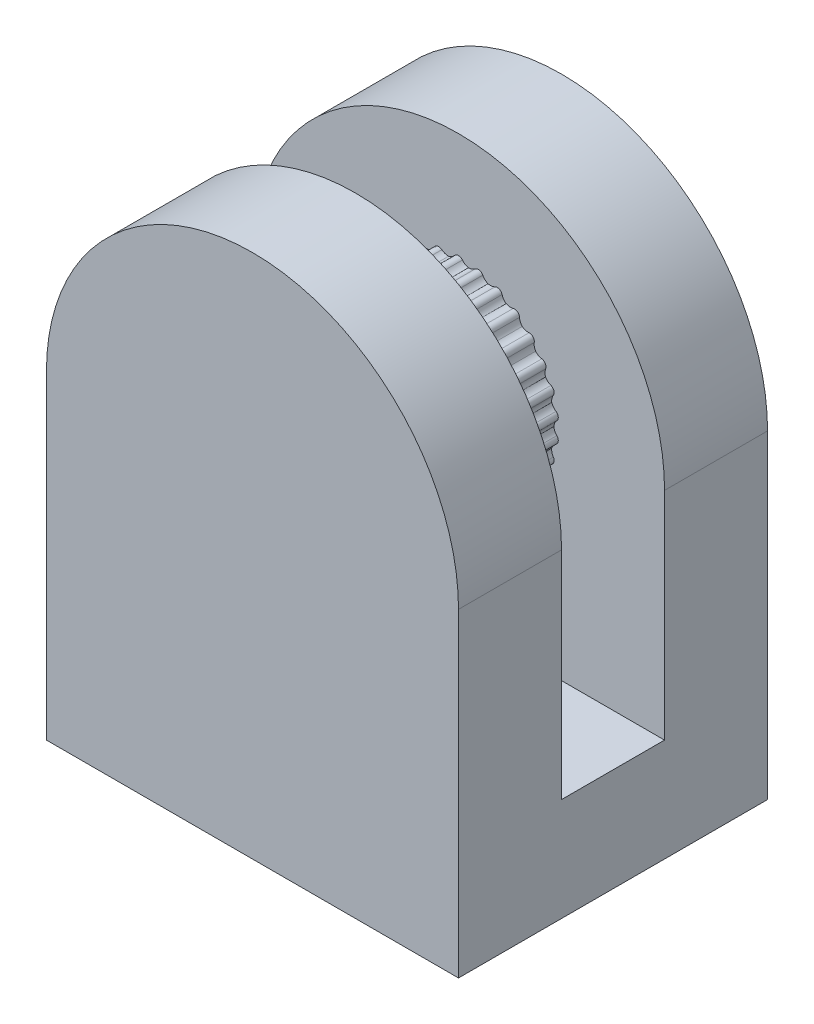
from build123d import *

# Parameters (mm, degrees)
BOSS_EXTRUDE1_DEPTH = 10
BOSS_EXTRUDE2_DEPTH = 10
SKETCH3_W           = 40
SKETCH3_H           = 10
BOSS_EXTRUDE3_DEPTH = 10


with BuildPart() as part:
    # Sketch1 → Boss-Extrude1 (new body)
    with BuildSketch(Plane.XY):
        with BuildLine():
            ThreePointArc((0.378650208, 9.55600532), (0, 9.736842105), (-0.378650208, 9.55600532))
            ThreePointArc((-0.378650208, 9.55600532), (-0.641665483, 9.327218092), (-0.967233833, 9.202615203))
            ThreePointArc((-0.967233833, 9.202615203), (-1.311594131, 9.256805753), (-1.616429431, 9.425909481))
            ThreePointArc((-1.616429431, 9.425909481), (-2.024403305, 9.524068744), (-2.357181016, 9.268457871))
            ThreePointArc((-2.357181016, 9.268457871), (-2.566881237, 8.989986242), (-2.85942874, 8.800416759))
            ThreePointArc((-2.85942874, 8.800416759), (-3.207530788, 8.781826585), (-3.540863348, 8.883856167))
            ThreePointArc((-3.540863348, 8.883856167), (-3.960330472, 8.895047877), (-4.232691702, 8.575834338))
            ThreePointArc((-4.232691702, 8.575834338), (-4.379911963, 8.259848855), (-4.62665289, 8.013597874))
            ThreePointArc((-4.62665289, 8.013597874), (-4.963282959, 7.923039454), (-5.310544545, 7.95353571))
            ThreePointArc((-5.310544545, 7.95353571), (-5.723172193, 7.877270735), (-5.923213451, 7.508405694))
            ThreePointArc((-5.923213451, 7.508405694), (-6.00151952, 7.168716439), (-6.191670107, 6.876546309))
            ThreePointArc((-6.191670107, 6.876546309), (-6.502115847, 6.717977481), (-6.848129462, 6.675607576))
            ThreePointArc((-6.848129462, 6.675607576), (-7.235883827, 6.515219062), (-7.354862349, 6.112823691))
            ThreePointArc((-7.354862349, 6.112823691), (-7.360831875, 5.764276714), (-7.48608163, 5.438956672))
            ThreePointArc((-7.48608163, 5.438956672), (-7.756775072, 5.219307655), (-8.086418262, 5.105923359))
            ThreePointArc((-8.086418262, 5.105923359), (-8.432352616, 4.868421053), (-8.465068469, 4.450081961))
            ThreePointArc((-8.465068469, 4.450081961), (-8.398440555, 4.107910437), (-8.453315463, 3.76365853))
            ThreePointArc((-8.453315463, 3.76365853), (-8.672426006, 3.492529039), (-8.97129178, 3.31308579))
            ThreePointArc((-8.97129178, 3.31308579), (-9.260287132, 3.008849682), (-9.205310478, 2.592850295))
            ThreePointArc((-9.205310478, 2.592850295), (-9.068997084, 2.272008762), (-9.051098847, 1.92387045))
            ThreePointArc((-9.051098847, 1.92387045), (-9.209050308, 1.613110146), (-9.464076798, 1.375450473))
            ThreePointArc((-9.464076798, 1.375450473), (-9.683502665, 1.017777142), (-9.543236247, 0.622298629))
            ThreePointArc((-9.543236247, 0.622298629), (-9.343194922, 0.336809401), (-9.25330578, 0))
            ThreePointArc((-9.25330578, 0), (-9.343194922, -0.336809401), (-9.543236247, -0.622298629))
            ThreePointArc((-9.543236247, -0.622298629), (-9.683502665, -1.017777142), (-9.464076798, -1.375450473))
            ThreePointArc((-9.464076798, -1.375450473), (-9.209050308, -1.613110146), (-9.051098847, -1.92387045))
            ThreePointArc((-9.051098847, -1.92387045), (-9.068997084, -2.272008762), (-9.205310478, -2.592850295))
            ThreePointArc((-9.205310478, -2.592850295), (-9.260287132, -3.008849682), (-8.97129178, -3.31308579))
            ThreePointArc((-8.97129178, -3.31308579), (-8.672426006, -3.492529039), (-8.453315463, -3.76365853))
            ThreePointArc((-8.453315463, -3.76365853), (-8.398440555, -4.107910437), (-8.465068469, -4.450081961))
            ThreePointArc((-8.465068469, -4.450081961), (-8.432352616, -4.868421053), (-8.086418262, -5.105923359))
            ThreePointArc((-8.086418262, -5.105923359), (-7.756775072, -5.219307655), (-7.48608163, -5.438956672))
            ThreePointArc((-7.48608163, -5.438956672), (-7.360831875, -5.764276714), (-7.354862349, -6.112823691))
            ThreePointArc((-7.354862349, -6.112823691), (-7.235883827, -6.515219062), (-6.848129462, -6.675607576))
            ThreePointArc((-6.848129462, -6.675607576), (-6.502115847, -6.717977481), (-6.191670107, -6.876546309))
            ThreePointArc((-6.191670107, -6.876546309), (-6.00151952, -7.168716439), (-5.923213451, -7.508405694))
            ThreePointArc((-5.923213451, -7.508405694), (-5.723172193, -7.877270735), (-5.310544545, -7.95353571))
            ThreePointArc((-5.310544545, -7.95353571), (-4.963282959, -7.923039454), (-4.62665289, -8.013597874))
            ThreePointArc((-4.62665289, -8.013597874), (-4.379911963, -8.259848855), (-4.232691702, -8.575834338))
            ThreePointArc((-4.232691702, -8.575834338), (-3.960330472, -8.895047877), (-3.540863348, -8.883856167))
            ThreePointArc((-3.540863348, -8.883856167), (-3.207530788, -8.781826585), (-2.85942874, -8.800416759))
            ThreePointArc((-2.85942874, -8.800416759), (-2.566881237, -8.989986242), (-2.357181016, -9.268457871))
            ThreePointArc((-2.357181016, -9.268457871), (-2.024403305, -9.524068744), (-1.616429431, -9.425909481))
            ThreePointArc((-1.616429431, -9.425909481), (-1.311594131, -9.256805753), (-0.967233833, -9.202615203))
            ThreePointArc((-0.967233833, -9.202615203), (-0.641665483, -9.327218092), (-0.378650208, -9.55600532))
            ThreePointArc((-0.378650208, -9.55600532), (0, -9.736842105), (0.378650208, -9.55600532))
            ThreePointArc((0.378650208, -9.55600532), (0.641665483, -9.327218092), (0.967233833, -9.202615203))
            ThreePointArc((0.967233833, -9.202615203), (1.311594131, -9.256805753), (1.616429431, -9.425909481))
            ThreePointArc((1.616429431, -9.425909481), (2.024403305, -9.524068744), (2.357181016, -9.268457871))
            ThreePointArc((2.357181016, -9.268457871), (2.566881237, -8.989986242), (2.85942874, -8.800416759))
            ThreePointArc((2.85942874, -8.800416759), (3.207530788, -8.781826585), (3.540863348, -8.883856167))
            ThreePointArc((3.540863348, -8.883856167), (3.960330472, -8.895047877), (4.232691702, -8.575834338))
            ThreePointArc((4.232691702, -8.575834338), (4.379911963, -8.259848855), (4.62665289, -8.013597874))
            ThreePointArc((4.62665289, -8.013597874), (4.963282959, -7.923039454), (5.310544545, -7.95353571))
            ThreePointArc((5.310544545, -7.95353571), (5.723172193, -7.877270735), (5.923213451, -7.508405694))
            ThreePointArc((5.923213451, -7.508405694), (6.00151952, -7.168716439), (6.191670107, -6.876546309))
            ThreePointArc((6.191670107, -6.876546309), (6.502115847, -6.717977481), (6.848129462, -6.675607576))
            ThreePointArc((6.848129462, -6.675607576), (7.235883827, -6.515219062), (7.354862349, -6.112823691))
            ThreePointArc((7.354862349, -6.112823691), (7.360831875, -5.764276714), (7.48608163, -5.438956672))
            ThreePointArc((7.48608163, -5.438956672), (7.756775072, -5.219307655), (8.086418262, -5.105923359))
            ThreePointArc((8.086418262, -5.105923359), (8.432352616, -4.868421053), (8.465068469, -4.450081961))
            ThreePointArc((8.465068469, -4.450081961), (8.398440555, -4.107910437), (8.453315463, -3.76365853))
            ThreePointArc((8.453315463, -3.76365853), (8.672426006, -3.492529039), (8.97129178, -3.31308579))
            ThreePointArc((8.97129178, -3.31308579), (9.260287132, -3.008849682), (9.205310478, -2.592850295))
            ThreePointArc((9.205310478, -2.592850295), (9.068997084, -2.272008762), (9.051098847, -1.92387045))
            ThreePointArc((9.051098847, -1.92387045), (9.209050308, -1.613110146), (9.464076798, -1.375450473))
            ThreePointArc((9.464076798, -1.375450473), (9.683502665, -1.017777142), (9.543236247, -0.622298629))
            ThreePointArc((9.543236247, -0.622298629), (9.343194922, -0.336809401), (9.25330578, 0))
            ThreePointArc((9.25330578, 0), (9.343194922, 0.336809401), (9.543236247, 0.622298629))
            ThreePointArc((9.543236247, 0.622298629), (9.683502665, 1.017777142), (9.464076798, 1.375450473))
            ThreePointArc((9.464076798, 1.375450473), (9.209050308, 1.613110146), (9.051098847, 1.92387045))
            ThreePointArc((9.051098847, 1.92387045), (9.068997084, 2.272008762), (9.205310478, 2.592850295))
            ThreePointArc((9.205310478, 2.592850295), (9.260287132, 3.008849682), (8.97129178, 3.31308579))
            ThreePointArc((8.97129178, 3.31308579), (8.672426006, 3.492529039), (8.453315463, 3.76365853))
            ThreePointArc((8.453315463, 3.76365853), (8.398440555, 4.107910437), (8.465068469, 4.450081961))
            ThreePointArc((8.465068469, 4.450081961), (8.432352616, 4.868421053), (8.086418262, 5.105923359))
            ThreePointArc((8.086418262, 5.105923359), (7.756775072, 5.219307655), (7.48608163, 5.438956672))
            ThreePointArc((7.48608163, 5.438956672), (7.360831875, 5.764276714), (7.354862349, 6.112823691))
            ThreePointArc((7.354862349, 6.112823691), (7.235883827, 6.515219062), (6.848129462, 6.675607576))
            ThreePointArc((6.848129462, 6.675607576), (6.502115847, 6.717977481), (6.191670107, 6.876546309))
            ThreePointArc((6.191670107, 6.876546309), (6.00151952, 7.168716439), (5.923213451, 7.508405694))
            ThreePointArc((5.923213451, 7.508405694), (5.723172193, 7.877270735), (5.310544545, 7.95353571))
            ThreePointArc((5.310544545, 7.95353571), (4.963282959, 7.923039454), (4.62665289, 8.013597874))
            ThreePointArc((4.62665289, 8.013597874), (4.379911963, 8.259848855), (4.232691702, 8.575834338))
            ThreePointArc((4.232691702, 8.575834338), (3.960330472, 8.895047877), (3.540863348, 8.883856167))
            ThreePointArc((3.540863348, 8.883856167), (3.207530788, 8.781826585), (2.85942874, 8.800416759))
            ThreePointArc((2.85942874, 8.800416759), (2.566881237, 8.989986242), (2.357181016, 9.268457871))
            ThreePointArc((2.357181016, 9.268457871), (2.024403305, 9.524068744), (1.616429431, 9.425909481))
            ThreePointArc((1.616429431, 9.425909481), (1.311594131, 9.256805753), (0.967233833, 9.202615203))
            ThreePointArc((0.967233833, 9.202615203), (0.641665483, 9.327218092), (0.378650208, 9.55600532))
        make_face()
    extrude(amount=BOSS_EXTRUDE1_DEPTH)

    # Sketch2 → Boss-Extrude2 (add)
    with BuildSketch(Plane(origin=(0, 0, 0), x_dir=(-1, 0, 0), z_dir=(0, 0, -1))):
        with BuildLine():
            Line((-20, 0), (-20, -30.991945279))
            Line((-20, -30.991945279), (20, -30.991945279))
            Line((20, -30.991945279), (20, 0))
            ThreePointArc((20, 0), (0, 20), (-20, 0))
        make_face()
    boss_extrude2 = extrude(amount=BOSS_EXTRUDE2_DEPTH)

    # Mirror2: Boss-Extrude2 across plane
    add(boss_extrude2.mirror(Plane.XY.offset(5)))

    # Sketch3 → Boss-Extrude3 (add)
    with BuildSketch(Plane(origin=(0, 0, 10), x_dir=(-1, 0, 0), z_dir=(0, 0, -1))):
        with Locations((0, -25.991945279)):
            Rectangle(SKETCH3_W, SKETCH3_H)
    extrude(amount=BOSS_EXTRUDE3_DEPTH)


solid = part.part
